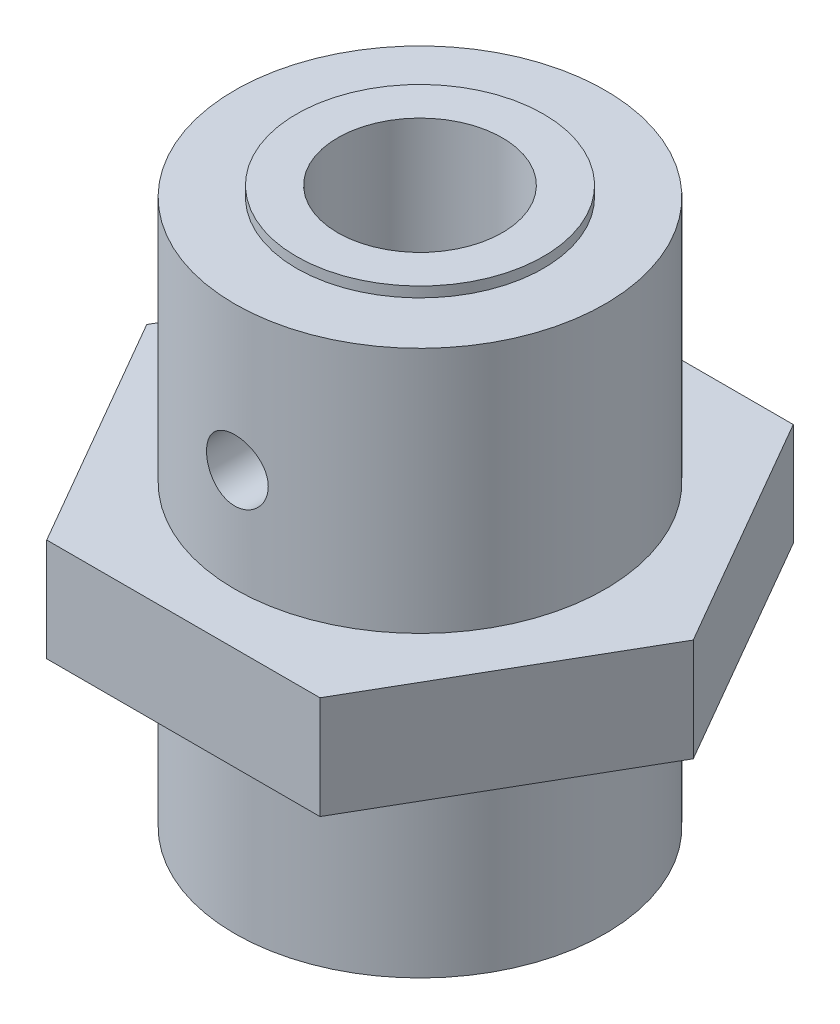
from build123d import *

# Parameters (mm, degrees)
SKETCH1_R               = 9
SKETCH1_R_2             = 4
BOSS_EXTRUDE1_DEPTH     = 27
SKETCH2_R               = 9
SKETCH2_R_2             = 6
CUT_EXTRUDE1_DEPTH      = 0.5
SKETCH3_R               = 1.5
CUT_EXTRUDE2_DEPTH      = 10
CUT_EXTRUDE2_DEPTH_BACK = 10
SKETCH4_R               = 4
BOSS_EXTRUDE2_DEPTH     = 5


with BuildPart() as part:
    # Sketch1 → Boss-Extrude1 (new body)
    with BuildSketch(Plane(origin=(0, 0, 0), x_dir=(1, 0, 0), z_dir=(0, 1, 0))):
        Circle(SKETCH1_R)
        Circle(SKETCH1_R_2, mode=Mode.SUBTRACT)
    extrude(amount=BOSS_EXTRUDE1_DEPTH)

    # Sketch2 → Cut-Extrude1 (cut)
    with BuildSketch(Plane(origin=(0, 27, 0), x_dir=(1, 0, 0), z_dir=(0, 1, 0))):
        Circle(SKETCH2_R)
        Circle(SKETCH2_R_2, mode=Mode.SUBTRACT)
    extrude(amount=-CUT_EXTRUDE1_DEPTH, mode=Mode.SUBTRACT)

    # Sketch3 → Cut-Extrude2 (cut, two sides)
    with BuildSketch(Plane.XY) as cut_extrude2_sk:
        with Locations((0, 19.5)):
            Circle(SKETCH3_R)
    extrude(amount=CUT_EXTRUDE2_DEPTH, mode=Mode.SUBTRACT)
    extrude(cut_extrude2_sk.sketch, amount=-CUT_EXTRUDE2_DEPTH_BACK, mode=Mode.SUBTRACT)

    # Sketch4 → Boss-Extrude2 (add)
    with BuildSketch(Plane(origin=(0, 14.5, 0), x_dir=(1, 0, 0), z_dir=(0, 1, 0))):
        Polygon((13.279056191, 0), (6.639528096, 11.5), (-6.639528096, 11.5), (-13.279056191, 0), (-6.639528096, -11.5), (6.639528096, -11.5), align=None)
        Circle(SKETCH4_R, mode=Mode.SUBTRACT)
    extrude(amount=-BOSS_EXTRUDE2_DEPTH)


solid = part.part
